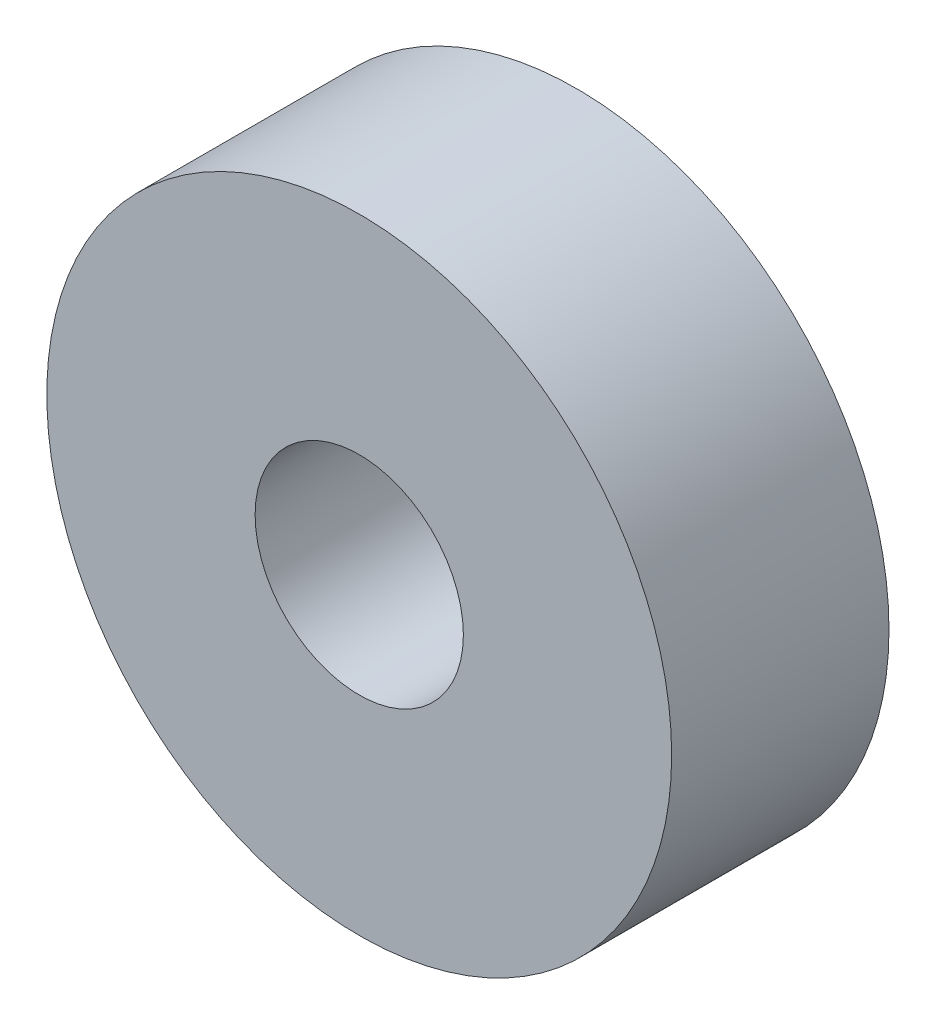
from build123d import *

# Parameters (mm, degrees)
SKETCH1_R           = 4.3815
SKETCH1_R_2         = 1.4605
BOSS_EXTRUDE1_DEPTH = 3.048


with BuildPart() as part:
    # Sketch1 → Boss-Extrude1 (new body)
    with BuildSketch(Plane.XY):
        Circle(SKETCH1_R)
        Circle(SKETCH1_R_2, mode=Mode.SUBTRACT)
    extrude(amount=BOSS_EXTRUDE1_DEPTH)


solid = part.part
